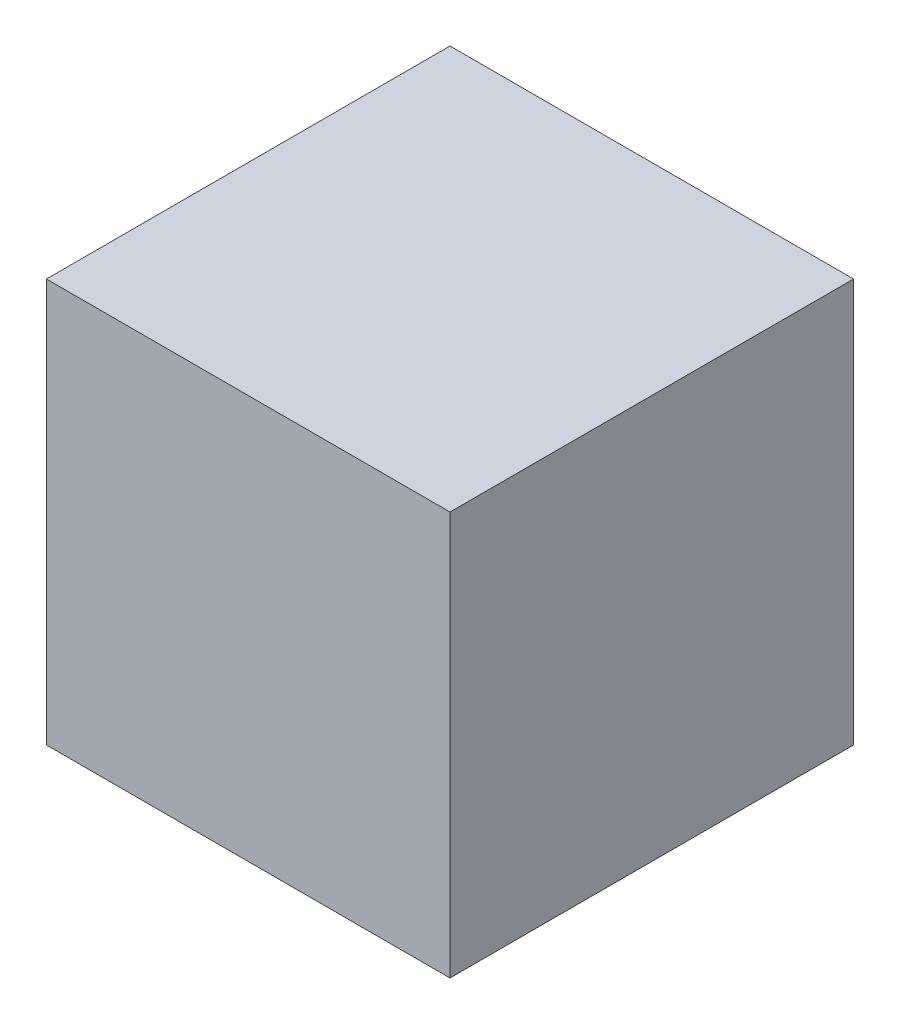
from build123d import *

# Parameters (mm, degrees)
SKETCH1_W           = 100
SKETCH1_H           = 100
BOSS_EXTRUDE1_DEPTH = 50


with BuildPart() as part:
    # Sketch1 → Boss-Extrude1 (new body, symmetric)
    with BuildSketch(Plane(origin=(0, 0, 0), x_dir=(1, 0, 0), z_dir=(0, 1, 0))):
        Rectangle(SKETCH1_W, SKETCH1_H)
    extrude(amount=BOSS_EXTRUDE1_DEPTH, both=True)


solid = part.part
